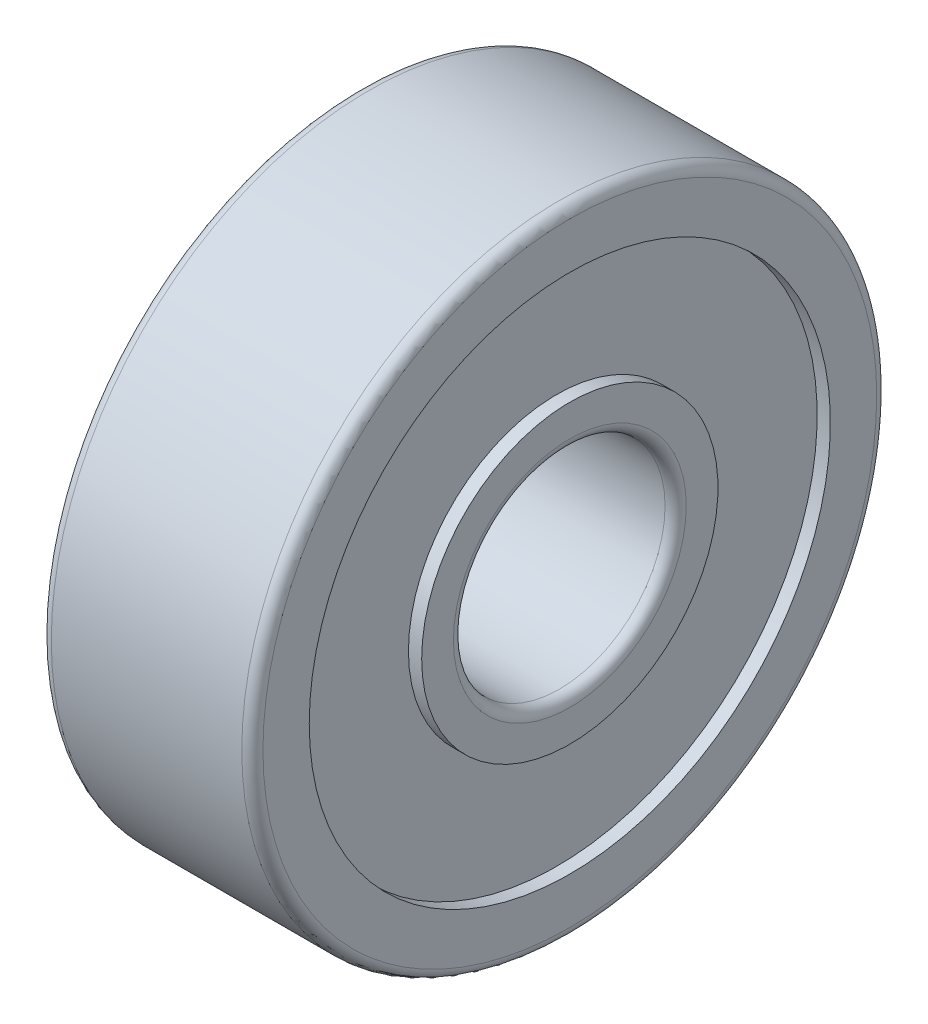
from build123d import *


with BuildPart() as part:
    # Sketch1 → Revolve1 (revolve)
    with BuildSketch(Plane.XY):
        with BuildLine():
            Line((0, 4.925), (0.25, 4.925))
            Line((0.25, 4.925), (0.25, 2.8))
            Line((0.25, 2.8), (0, 2.8))
            Line((0, 2.8), (0, 2.2))
            ThreePointArc((0, 2.2), (0.058578644, 2.058578644), (0.2, 2))
            Line((0.2, 2), (3.8, 2))
            ThreePointArc((3.8, 2), (3.941421356, 2.058578644), (4, 2.2))
            Line((4, 2.2), (4, 2.8))
            Line((4, 2.8), (3.75, 2.8))
            Line((3.75, 2.8), (3.75, 4.925))
            Line((3.75, 4.925), (4, 4.925))
            Line((4, 4.925), (4, 5.8))
            ThreePointArc((4, 5.8), (3.941421356, 5.941421356), (3.8, 6))
            Line((3.8, 6), (0.2, 6))
            ThreePointArc((0.2, 6), (0.058578644, 5.941421356), (0, 5.8))
            Line((0, 5.8), (0, 4.925))
        make_face()
    revolve(axis=Axis((-0.2, 0, 0), (1, 0, 0)))


solid = part.part
